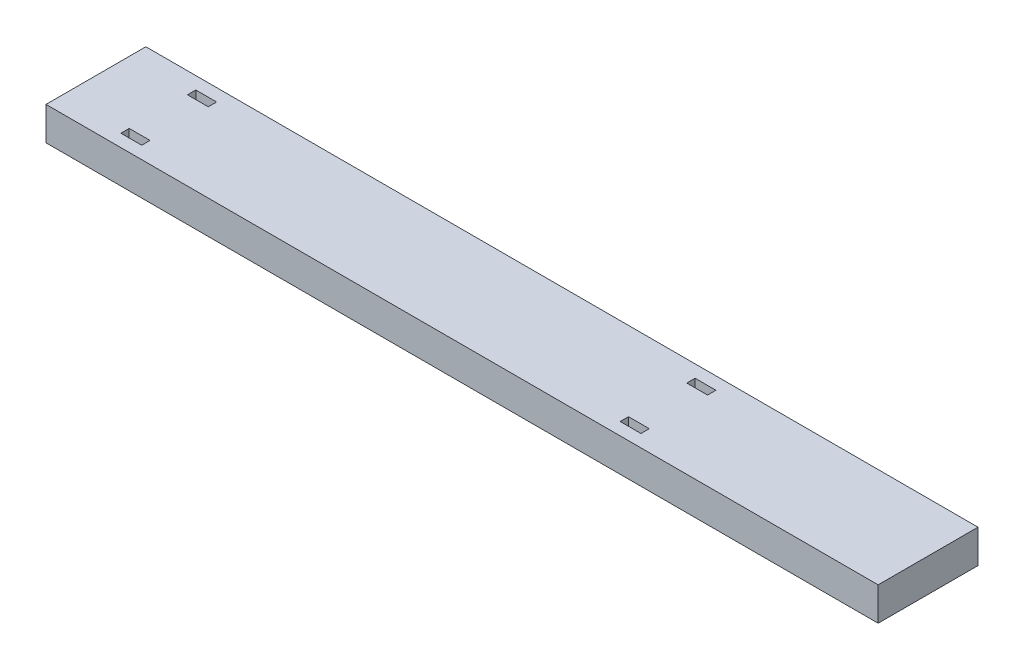
from build123d import *

# Parameters (mm, degrees)
SKETCH1_W           = 200
SKETCH1_H           = 24
BOSS_EXTRUDE2_DEPTH = 8
SKETCH2_W           = 5
SKETCH2_H           = 2
CUT_EXTRUDE1_DEPTH  = 9


with BuildPart() as part:
    # Sketch1 → Boss-Extrude2 (new body)
    with BuildSketch(Plane(origin=(0, 0, 0), x_dir=(1, 0, 0), z_dir=(0, 1, 0))):
        with Locations((100, 12)):
            Rectangle(SKETCH1_W, SKETCH1_H)
    extrude(amount=BOSS_EXTRUDE2_DEPTH)

    # Sketch2 → Cut-Extrude1 (cut, through all)
    with BuildSketch(Plane(origin=(0, 8, 0), x_dir=(1, 0, 0), z_dir=(0, 1, 0))):
        with Locations((17.5, 20)):
            Rectangle(SKETCH2_W, SKETCH2_H)
        with Locations((137.5, 20)):
            Rectangle(SKETCH2_W, SKETCH2_H)
        with Locations((137.5, 4)):
            Rectangle(SKETCH2_W, SKETCH2_H)
        with Locations((17.5, 4)):
            Rectangle(SKETCH2_W, SKETCH2_H)
    extrude(amount=-CUT_EXTRUDE1_DEPTH, mode=Mode.SUBTRACT)


solid = part.part
